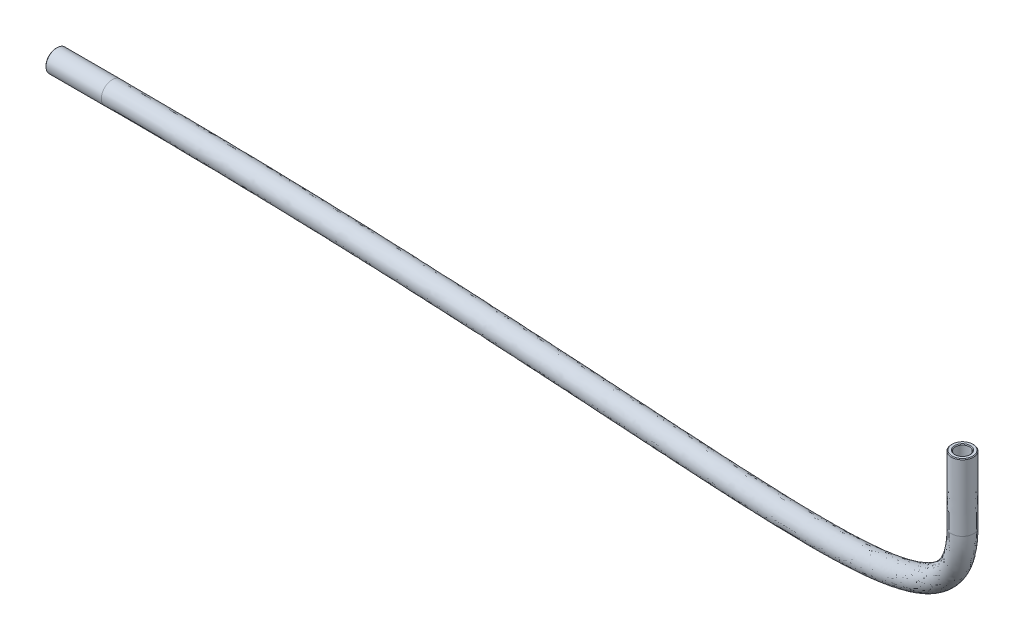
from build123d import *

# Parameters (mm, degrees)
SKETCH1_R     = 2
SKETCH1_R_2   = 1.3
CHAMFER1_SIZE = 0.127


with BuildPart() as part:
    # Sweep1: sweep along a curve in space
    with BuildLine() as sweep1_path:
        Line((41.325, -62.125, 13.85), (41.325, -74.325, 13.85))
        add(Edge.make_bspline(
            [(41.325, -74.325, 13.85), (41.325, -86.346418365, 13.85), (9.919600667, -103.338845801, 2.1625), (-78.1565683, -106.482256564, -9.525), (-136.885279081, -106.482256564, -9.525)],
            knots=[0, 0, 0, 0, 0.47810689, 1, 1, 1, 1], degree=3))
        Line((-136.885279081, -106.482256564, -9.525), (-147.085279081, -106.482256564, -9.525))
    # Sketch1 → Sweep1 (sweep)
    with BuildSketch(Plane(origin=(-138.985279081, 0, 0), x_dir=(0, 0, -1), z_dir=(1, 0, 0))):
        with Locations((9.525, -106.482256564)):
            Circle(SKETCH1_R)
        with Locations((9.525, -106.482256564)):
            Circle(SKETCH1_R_2, mode=Mode.SUBTRACT)
    sweep(path=sweep1_path.line)

    # Chamfer1
    chamfer1_edges = [part.edges().sort_by_distance(p)[0] for p in [
        (40.993171966, -62.125, 15.106936815),
        (-147.085279081, -106.482256564, -8.225),
        (40.814495333, -62.125, 15.783748946),
        (-147.085279081, -106.482256564, -7.525),
    ]]
    chamfer(chamfer1_edges, length=CHAMFER1_SIZE)


solid = part.part
